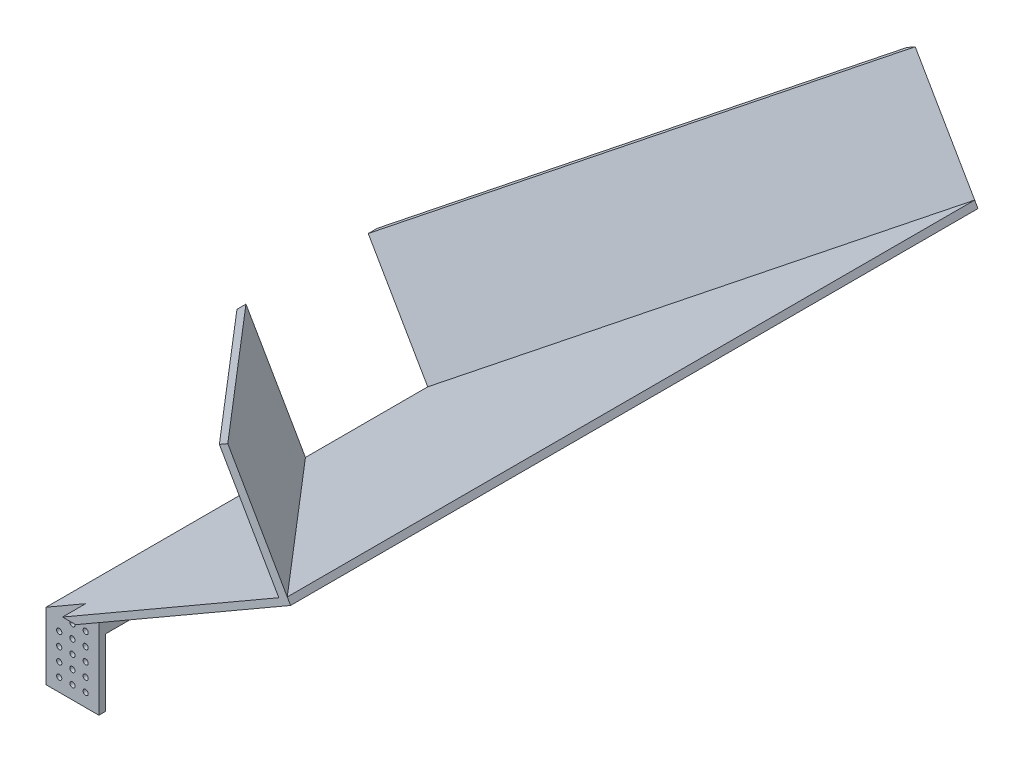
from build123d import *

# Parameters (mm, degrees)
SKETCH1_R           = 2.4892
BOSS_EXTRUDE1_DEPTH = 660.4
SKETCH2_W           = 596.9
SKETCH2_H           = 64.482348419
SKETCH2_W_2         = 28.575
SKETCH2_H_2         = 86.479393675
SKETCH2_W_3         = 22.225
CUT_EXTRUDE1_DEPTH  = 660.4
BOSS_EXTRUDE3_DEPTH = 114.3


with BuildPart() as part:
    # Sketch1 → Boss-Extrude1 (new body)
    with BuildSketch(Plane.XY):
        Polygon((0, 64.482348419), (0, 0), (50.8, 0), (50.8, 86.479393675), (257.175, 205.630055479), (254, 211.129316793), align=None)
        with Locations((38.1, 63.5)):
            Circle(SKETCH1_R, mode=Mode.SUBTRACT)
        with Locations((12.7, 12.7)):
            Circle(SKETCH1_R, mode=Mode.SUBTRACT)
        with Locations((25.4, 12.7)):
            Circle(SKETCH1_R, mode=Mode.SUBTRACT)
        with Locations((12.7, 25.4)):
            Circle(SKETCH1_R, mode=Mode.SUBTRACT)
        with Locations((25.4, 25.4)):
            Circle(SKETCH1_R, mode=Mode.SUBTRACT)
        with Locations((38.1, 12.7)):
            Circle(SKETCH1_R, mode=Mode.SUBTRACT)
        with Locations((38.1, 25.4)):
            Circle(SKETCH1_R, mode=Mode.SUBTRACT)
        with Locations((12.7, 38.1)):
            Circle(SKETCH1_R, mode=Mode.SUBTRACT)
        with Locations((25.4, 38.1)):
            Circle(SKETCH1_R, mode=Mode.SUBTRACT)
        with Locations((12.7, 50.8)):
            Circle(SKETCH1_R, mode=Mode.SUBTRACT)
        with Locations((25.4, 50.8)):
            Circle(SKETCH1_R, mode=Mode.SUBTRACT)
        with Locations((38.1, 38.1)):
            Circle(SKETCH1_R, mode=Mode.SUBTRACT)
        with Locations((38.1, 50.8)):
            Circle(SKETCH1_R, mode=Mode.SUBTRACT)
        with Locations((25.4, 63.5)):
            Circle(SKETCH1_R, mode=Mode.SUBTRACT)
    extrude(amount=BOSS_EXTRUDE1_DEPTH)

    # Sketch2 → Cut-Extrude1 (cut)
    with BuildSketch(Plane.ZY):
        with Locations((333.375, 32.24117421)):
            Rectangle(SKETCH2_W, SKETCH2_H)
        with Locations((14.2875, 43.239696838)):
            Rectangle(SKETCH2_W_2, SKETCH2_H_2)
        with Locations((649.2875, 43.239696838)):
            Rectangle(SKETCH2_W_3, SKETCH2_H_2)
    extrude(amount=-CUT_EXTRUDE1_DEPTH, mode=Mode.SUBTRACT)

    # Sketch4 → Boss-Extrude3 (add)
    with BuildSketch(Plane(origin=(-27.921675913, 48.361761314, 0), x_dir=(0.866025404, 0.5, 0), z_dir=(-0.5, 0.866025404, 0))):
        Polygon((325.535110958, 0), (32.241174209, -271.4625), (32.241174209, -262.810010594), (316.186774887, 0), align=None)
        Polygon((325.535110958, -660.4), (316.186774887, -660.4), (32.241174209, -397.589989406), (32.241174209, -388.9375), align=None)
    extrude(amount=BOSS_EXTRUDE3_DEPTH)


solid = part.part
